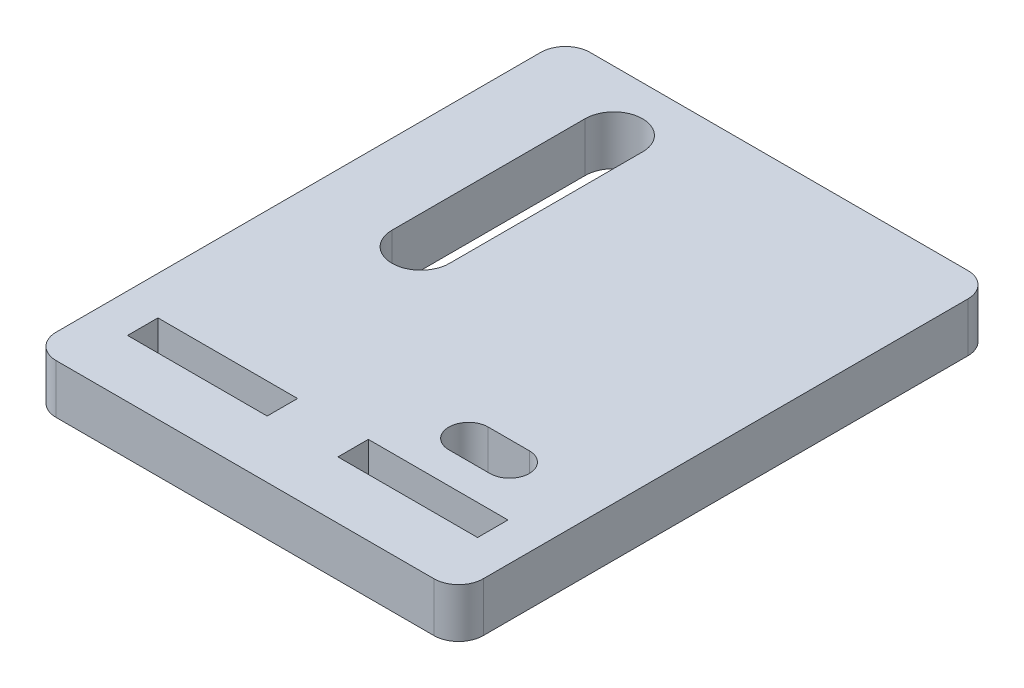
from build123d import *

# Parameters (mm, degrees)
SKETCH1_W           = 52
SKETCH1_H           = 65
BOSS_EXTRUDE1_DEPTH = 6
FILLET1_R           = 3
SKETCH4_W           = 17
SKETCH4_H           = 3.7
CUT_EXTRUDE1_DEPTH  = 7
CUT_EXTRUDE2_DEPTH  = 7
CUT_EXTRUDE3_DEPTH  = 7


with BuildPart() as part:
    # Sketch1 → Boss-Extrude1 (new body)
    with BuildSketch(Plane(origin=(0, 0, 0), x_dir=(1, 0, 0), z_dir=(0, 1, 0))):
        Rectangle(SKETCH1_W, SKETCH1_H)
    extrude(amount=BOSS_EXTRUDE1_DEPTH)

    # Fillet1
    fillet1_edges = [part.edges().sort_by_distance(p)[0] for p in [
        (26, 3, 32.5),
        (-26, 3, 32.5),
        (-26, 3, -32.5),
        (26, 3, -32.5),
    ]]
    fillet(fillet1_edges, radius=FILLET1_R)

    # Sketch4 → Cut-Extrude1 (cut, through all)
    with BuildSketch(Plane(origin=(0, 6, 0), x_dir=(1, 0, 0), z_dir=(0, 1, 0))):
        with Locations((-12.807771524, -23.65)):
            Rectangle(SKETCH4_W, SKETCH4_H)
    cut_extrude1 = extrude(amount=-CUT_EXTRUDE1_DEPTH, mode=Mode.SUBTRACT)

    # Mirror2: Cut-Extrude1 across plane
    add(cut_extrude1.mirror(Plane(origin=(0, 0, 0), x_dir=(0, 0, 1), z_dir=(1, 0, 0))), mode=Mode.SUBTRACT)

    # Sketch5 → Cut-Extrude2 (cut, through all)
    with BuildSketch(Plane(origin=(0, 6, 0), x_dir=(1, 0, 0), z_dir=(0, 1, 0))):
        with BuildLine():
            Line((10.307771524, -13.2), (15.307771524, -13.2))
            ThreePointArc((15.307771524, -13.2), (17.707771524, -15.6), (15.307771524, -18))
            Line((15.307771524, -18), (10.307771524, -18))
            ThreePointArc((10.307771524, -18), (7.907771524, -15.6), (10.307771524, -13.2))
        make_face()
    extrude(amount=-CUT_EXTRUDE2_DEPTH, mode=Mode.SUBTRACT)

    # Sketch6 → Cut-Extrude3 (cut, through all)
    with BuildSketch(Plane(origin=(0, 6, 0), x_dir=(1, 0, 0), z_dir=(0, 1, 0))):
        with BuildLine():
            Line((-9.307771524, 25.2), (-9.307771524, 1.7))
            ThreePointArc((-9.307771524, 1.7), (-12.807771524, -1.8), (-16.307771524, 1.7))
            Line((-16.307771524, 1.7), (-16.307771524, 25.2))
            ThreePointArc((-16.307771524, 25.2), (-12.807771524, 28.7), (-9.307771524, 25.2))
        make_face()
    extrude(amount=-CUT_EXTRUDE3_DEPTH, mode=Mode.SUBTRACT)


solid = part.part
